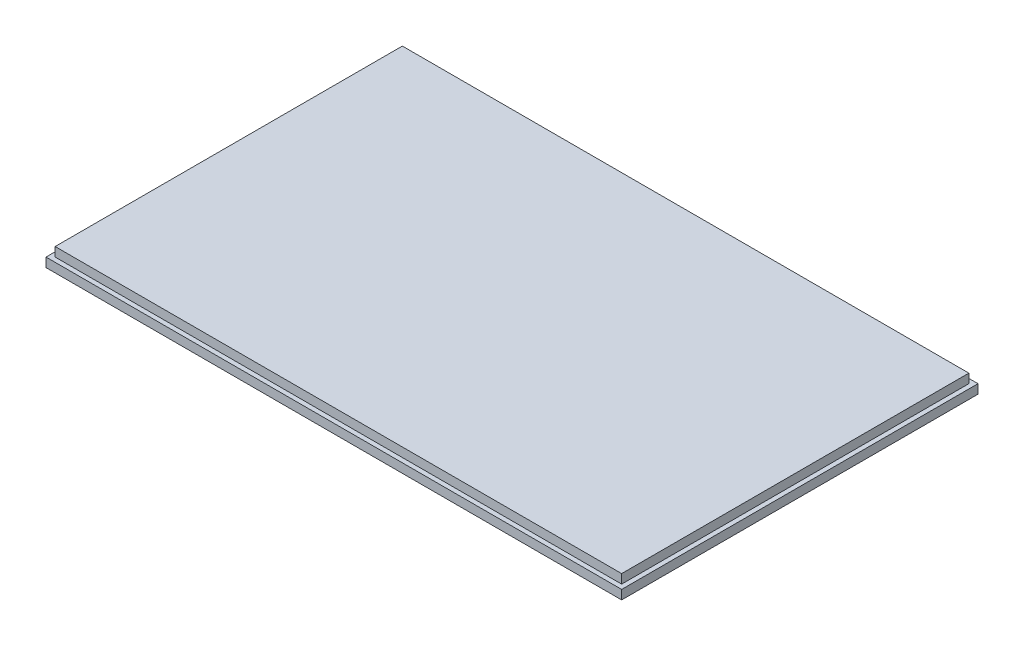
from build123d import *

# Parameters (mm, degrees)
SKETCH1_W           = 200.025
SKETCH1_H           = 123.825
BOSS_EXTRUDE1_DEPTH = 3.175
SKETCH2_W           = 196.85
SKETCH2_H           = 120.65
BOSS_EXTRUDE2_DEPTH = 3.175


with BuildPart() as part:
    # Sketch1 → Boss-Extrude1 (new body)
    with BuildSketch(Plane(origin=(0, 0, 0), x_dir=(1, 0, 0), z_dir=(0, 1, 0))):
        Rectangle(SKETCH1_W, SKETCH1_H)
    extrude(amount=BOSS_EXTRUDE1_DEPTH)

    # Sketch2 → Boss-Extrude2 (add)
    with BuildSketch(Plane(origin=(0, 3.175, 0), x_dir=(1, 0, 0), z_dir=(0, 1, 0))):
        Rectangle(SKETCH2_W, SKETCH2_H)
    extrude(amount=BOSS_EXTRUDE2_DEPTH)


solid = part.part
